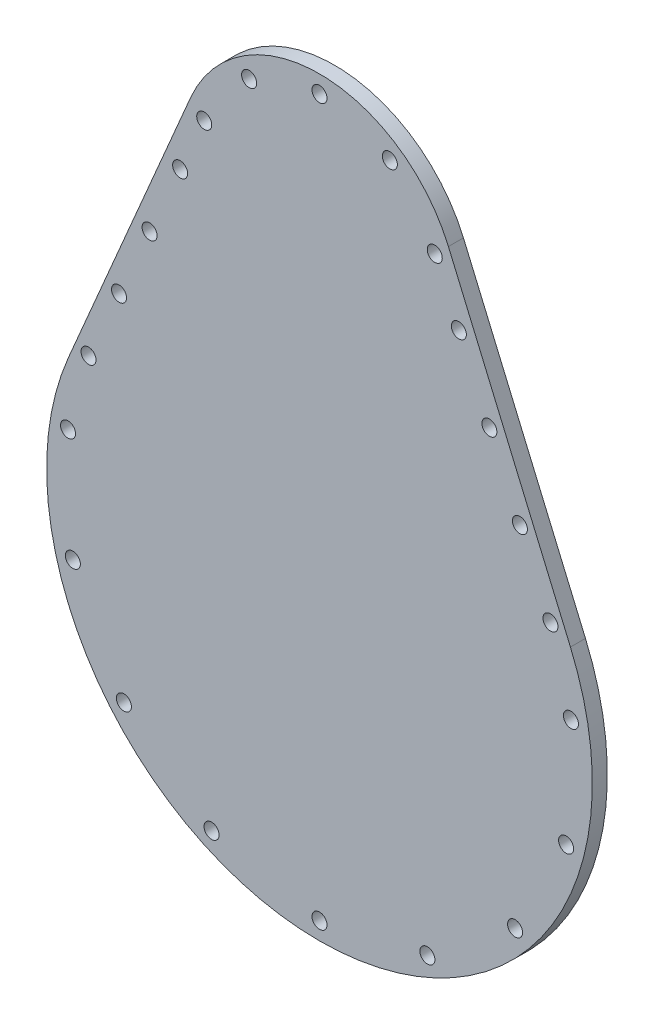
from build123d import *

# Parameters (mm, degrees)
SKETCH1_R           = 1.5
BOSS_EXTRUDE1_DEPTH = 3


with BuildPart() as part:
    # Sketch1 → Boss-Extrude1 (new body)
    with BuildSketch(Plane.XY):
        with BuildLine():
            Line((-25.751949598, 57.992592593), (-50.124330467, 0.896296296))
            ThreePointArc((-50.124330467, 0.896296296), (0, -75), (50.124330467, 0.896296296))
            Line((50.124330467, 0.896296296), (25.751949598, 57.992592593))
            ThreePointArc((25.751949598, 57.992592593), (0, 75), (-25.751949598, 57.992592593))
        make_face()
        with Locations((0, -71.5)):
            Circle(SKETCH1_R, mode=Mode.SUBTRACT)
        with Locations((0, 71.5)):
            Circle(SKETCH1_R, mode=Mode.SUBTRACT)
        with Locations((14.052622691, 67.069225085)):
            Circle(SKETCH1_R, mode=Mode.SUBTRACT)
        with Locations((23.022469209, 55.379493511)):
            Circle(SKETCH1_R, mode=Mode.SUBTRACT)
        with Locations((21.553531349, -66.721697139)):
            Circle(SKETCH1_R, mode=Mode.SUBTRACT)
        with Locations((39.068266599, -53.282168094)):
            Circle(SKETCH1_R, mode=Mode.SUBTRACT)
        with Locations((49.262217141, -33.6997713)):
            Circle(SKETCH1_R, mode=Mode.SUBTRACT)
        with Locations((50.225195404, -11.643942939)):
            Circle(SKETCH1_R, mode=Mode.SUBTRACT)
        with Locations((27.835315177, 44.555939465)):
            Circle(SKETCH1_R, mode=Mode.SUBTRACT)
        with Locations((33.935175216, 30.757307943)):
            Circle(SKETCH1_R, mode=Mode.SUBTRACT)
        with Locations((40.035035255, 16.95867642)):
            Circle(SKETCH1_R, mode=Mode.SUBTRACT)
        with Locations((46.134895294, 3.160044897)):
            Circle(SKETCH1_R, mode=Mode.SUBTRACT)
        with Locations((-46.134895294, 3.160044897)):
            Circle(SKETCH1_R, mode=Mode.SUBTRACT)
        with Locations((-40.035035255, 16.95867642)):
            Circle(SKETCH1_R, mode=Mode.SUBTRACT)
        with Locations((-33.935175216, 30.757307943)):
            Circle(SKETCH1_R, mode=Mode.SUBTRACT)
        with Locations((-27.835315177, 44.555939465)):
            Circle(SKETCH1_R, mode=Mode.SUBTRACT)
        with Locations((-50.225195404, -11.643942939)):
            Circle(SKETCH1_R, mode=Mode.SUBTRACT)
        with Locations((-49.262217141, -33.6997713)):
            Circle(SKETCH1_R, mode=Mode.SUBTRACT)
        with Locations((-39.068266599, -53.282168094)):
            Circle(SKETCH1_R, mode=Mode.SUBTRACT)
        with Locations((-21.553531349, -66.721697139)):
            Circle(SKETCH1_R, mode=Mode.SUBTRACT)
        with Locations((-23.022469209, 55.379493511)):
            Circle(SKETCH1_R, mode=Mode.SUBTRACT)
        with Locations((-14.052622691, 67.069225085)):
            Circle(SKETCH1_R, mode=Mode.SUBTRACT)
    extrude(amount=BOSS_EXTRUDE1_DEPTH)


solid = part.part
